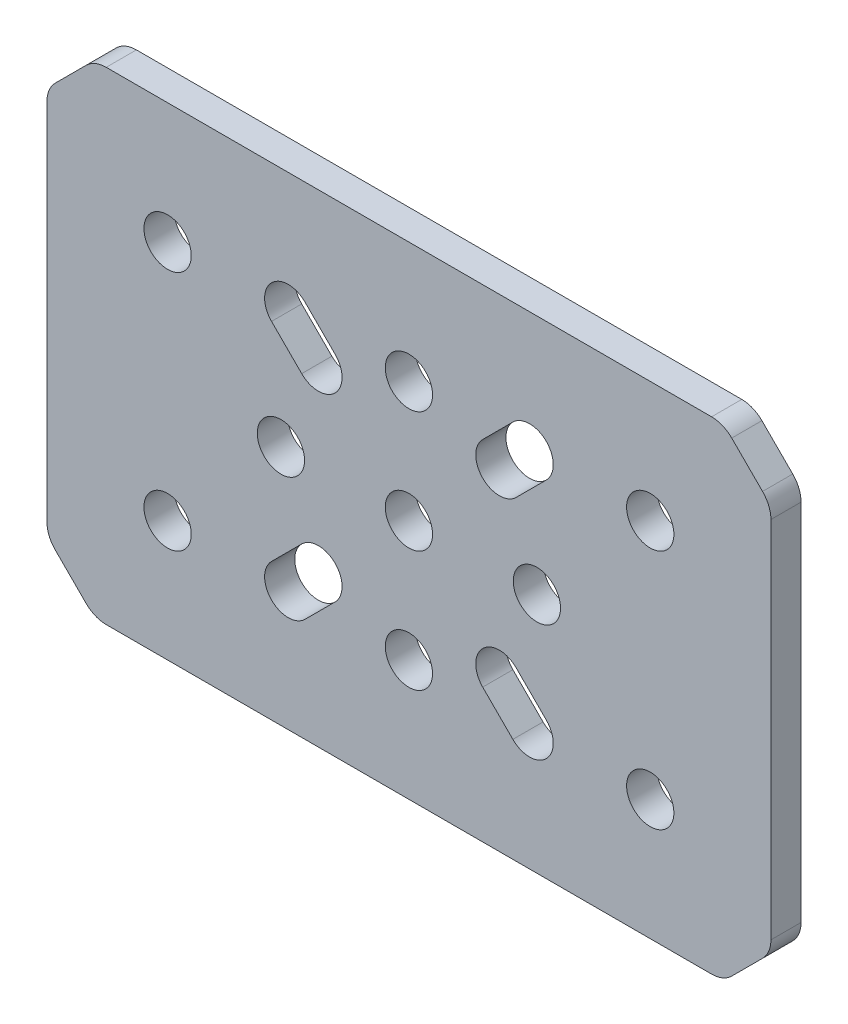
from build123d import *

# Parameters (mm, degrees)
SKETCH1_R           = 2.4892
BOSS_EXTRUDE1_DEPTH = 3.175


with BuildPart() as part:
    # Sketch1 → Boss-Extrude1 (new body)
    with BuildSketch(Plane.XY):
        with BuildLine():
            Line((33.978679656, -24.521320344), (37.221320344, -21.278679656))
            ThreePointArc((37.221320344, -21.278679656), (37.871638598, -20.30540961), (38.1, -19.157359313))
            Line((38.1, -19.157359313), (38.1, 19.157359313))
            ThreePointArc((38.1, 19.157359313), (37.871638598, 20.30540961), (37.221320344, 21.278679656))
            Line((37.221320344, 21.278679656), (33.978679656, 24.521320344))
            ThreePointArc((33.978679656, 24.521320344), (33.00540961, 25.171638598), (31.857359313, 25.4))
            Line((31.857359313, 25.4), (-31.857359313, 25.4))
            ThreePointArc((-31.857359313, 25.4), (-33.00540961, 25.171638598), (-33.978679656, 24.521320344))
            Line((-33.978679656, 24.521320344), (-37.221320344, 21.278679656))
            ThreePointArc((-37.221320344, 21.278679656), (-37.871638598, 20.30540961), (-38.1, 19.157359313))
            Line((-38.1, 19.157359313), (-38.1, -19.157359313))
            ThreePointArc((-38.1, -19.157359313), (-37.871638598, -20.30540961), (-37.221320344, -21.278679656))
            Line((-37.221320344, -21.278679656), (-33.978679656, -24.521320344))
            ThreePointArc((-33.978679656, -24.521320344), (-33.00540961, -25.171638598), (-31.857359313, -25.4))
            Line((-31.857359313, -25.4), (31.857359313, -25.4))
            ThreePointArc((31.857359313, -25.4), (33.00540961, -25.171638598), (33.978679656, -24.521320344))
        make_face()
        with Locations((13.470384182, 0)):
            Circle(SKETCH1_R, mode=Mode.SUBTRACT)
        with Locations((-25.4, 12.7)):
            Circle(SKETCH1_R, mode=Mode.SUBTRACT)
        with Locations((25.4, 12.7)):
            Circle(SKETCH1_R, mode=Mode.SUBTRACT)
        with Locations((25.4, -12.7)):
            Circle(SKETCH1_R, mode=Mode.SUBTRACT)
        with Locations((0, -12.7)):
            Circle(SKETCH1_R, mode=Mode.SUBTRACT)
        with Locations((-25.4, -12.7)):
            Circle(SKETCH1_R, mode=Mode.SUBTRACT)
        with Locations((0, 12.7)):
            Circle(SKETCH1_R, mode=Mode.SUBTRACT)
        Circle(SKETCH1_R, mode=Mode.SUBTRACT)
        with Locations((-13.470384182, 0)):
            Circle(SKETCH1_R, mode=Mode.SUBTRACT)
        with BuildLine():
            Line((11.2851302, -7.7648698), (14.4601302, -10.9398698))
            ThreePointArc((14.4601302, -10.9398698), (14.4601302, -14.4601302), (10.9398698, -14.4601302))
            Line((10.9398698, -14.4601302), (7.7648698, -11.2851302))
            ThreePointArc((7.7648698, -11.2851302), (7.7648698, -7.7648698), (11.2851302, -7.7648698))
        make_face(mode=Mode.SUBTRACT)
        with BuildLine():
            Line((-10.9398698, 14.4601302), (-7.7648698, 11.2851302))
            ThreePointArc((-7.7648698, 11.2851302), (-7.7648698, 7.7648698), (-11.2851302, 7.7648698))
            Line((-11.2851302, 7.7648698), (-14.4601302, 10.9398698))
            ThreePointArc((-14.4601302, 10.9398698), (-14.4601302, 14.4601302), (-10.9398698, 14.4601302))
        make_face(mode=Mode.SUBTRACT)
        with BuildLine():
            Line((-7.7648698, -11.2851302), (-10.9398698, -14.4601302))
            ThreePointArc((-10.9398698, -14.4601302), (-14.4601302, -14.4601302), (-14.4601302, -10.9398698))
            Line((-14.4601302, -10.9398698), (-11.2851302, -7.7648698))
            ThreePointArc((-11.2851302, -7.7648698), (-7.7648698, -7.7648698), (-7.7648698, -11.2851302))
        make_face(mode=Mode.SUBTRACT)
        with BuildLine():
            Line((14.4601302, 10.9398698), (11.2851302, 7.7648698))
            ThreePointArc((11.2851302, 7.7648698), (7.7648698, 7.7648698), (7.7648698, 11.2851302))
            Line((7.7648698, 11.2851302), (10.9398698, 14.4601302))
            ThreePointArc((10.9398698, 14.4601302), (14.4601302, 14.4601302), (14.4601302, 10.9398698))
        make_face(mode=Mode.SUBTRACT)
    extrude(amount=-BOSS_EXTRUDE1_DEPTH)


solid = part.part
